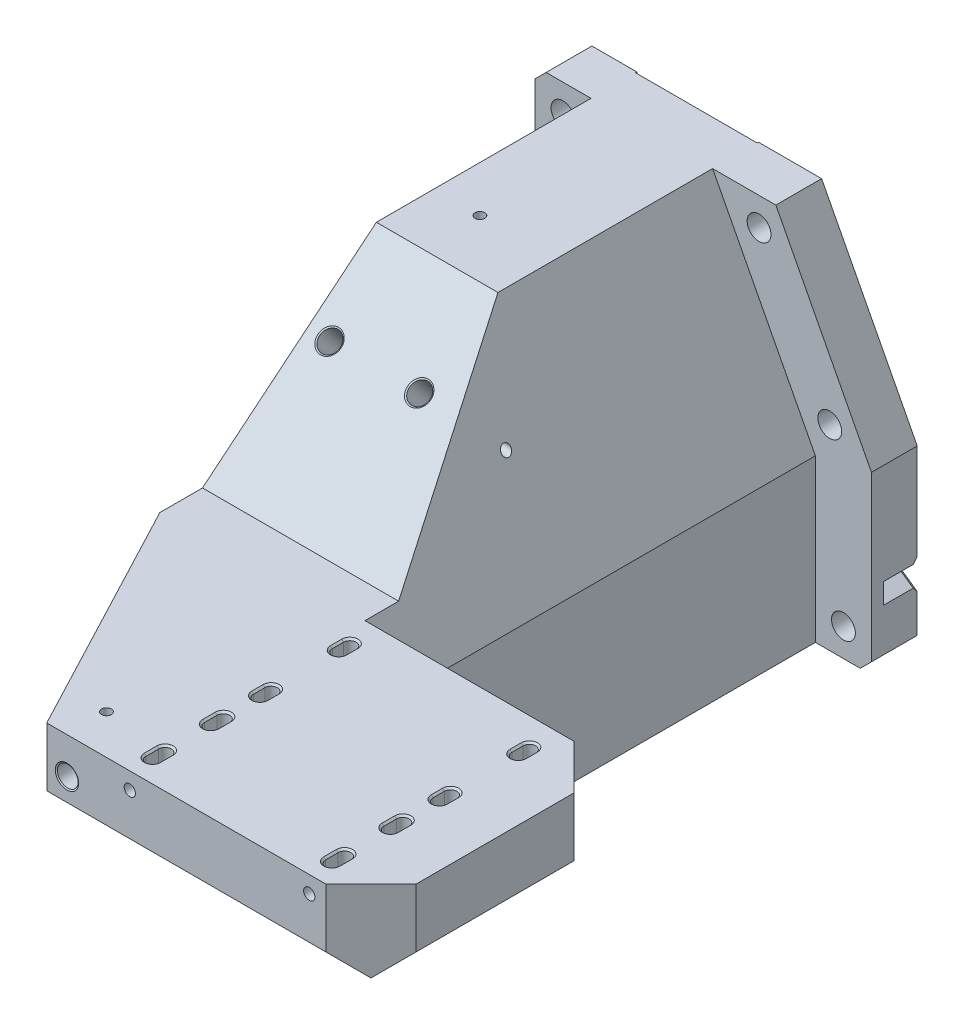
from build123d import *

# Parameters (mm, degrees)
SKETCH1_W                                   = 254.635
SKETCH1_H                                   = 101.6
EXTRUDE1_DEPTH                              = 341.0712
CUT_EXTRUDE2_DEPTH                          = 1
CUT_EXTRUDE2_DEPTH_BACK                     = 102.6
SKETCH2_W                                   = 31.75
SKETCH2_H                                   = 101.6
EXTRUDE2_DEPTH                              = 25.908
CUT_EXTRUDE15_DEPTH                         = 102.6
SKETCH36_W                                  = 176.53
SKETCH36_H                                  = 69.85
CUT_EXTRUDE19_DEPTH                         = 6.35
CUT_EXTRUDE22_DEPTH                         = 82.55
CUT_EXTRUDE23_DEPTH                         = 1
CUT_EXTRUDE23_DEPTH_BACK                    = 102.6
SKETCH46_W                                  = 190.5
SKETCH46_H                                  = 25.908
EXTRUDE7_DEPTH                              = 101.6
EXTRUDE8_DEPTH                              = 127
CUT_EXTRUDE26_DEPTH                         = 101.6
CUT_EXTRUDE27_DEPTH                         = 79.375
CUT_EXTRUDE28_DEPTH                         = 38.9382
CUT_EXTRUDE30_DEPTH                         = 26.908
EXTRUDE9_DEPTH                              = 82.55
SKETCH58_W                                  = 48.895
SKETCH58_H                                  = 6.35
CUT_EXTRUDE34_DEPTH                         = 3.175
SKETCH59_W                                  = 127.635
SKETCH59_H                                  = 95.25
EXTRUDE10_DEPTH                             = 25.4
EXTRUDE11_DEPTH                             = 26.924
SKETCH64_W                                  = 183.515
SKETCH64_H                                  = 122.174
EXTRUDE12_DEPTH                             = 64.008
EXTRUDE13_DEPTH                             = 123.174
LPATTERN2_COUNT                             = 2
LPATTERN2_PITCH                             = 101.6
LPATTERN2_COUNT_DIR2                        = 2
LPATTERN2_PITCH_DIR2                        = 33.02
EXTRUDE17_DEPTH                             = 122.174
EXTRUDE18_DEPTH                             = 255.635
EXTRUDE19_REACH                             = 256.635
EXTRUDE20_DEPTH                             = 406.0792
EXTRUDE21_DEPTH                             = 19.05
CHAMFER3_SIZE                               = 25.4
TAPPED_HOLE_FOR_3_8_16_HELICOIL2_AT_2_COUNT = 2
TAPPED_HOLE_FOR_3_8_16_HELICOIL2_AT_2_PITCH = 50.8
TAPPED_HOLE_FOR_3_8_16_HELICOIL1_AT_2_COUNT = 2
TAPPED_HOLE_FOR_3_8_16_HELICOIL1_AT_2_PITCH = 50.8
TAPPED_HOLE_FOR_3_8_16_HELICOIL1_AT_3_COUNT = 2
TAPPED_HOLE_FOR_3_8_16_HELICOIL1_AT_3_PITCH = 126.55752319
TAPPED_HOLE_FOR_3_8_16_HELICOIL1_AT_4_COUNT = 2
TAPPED_HOLE_FOR_3_8_16_HELICOIL1_AT_4_PITCH = 86.45743621
F_7_32_0_21875_DIAMETER_HOLE1_D             = 5.55625
F_7_32_0_21875_DIAMETER_HOLE3_D             = 5.55625
F_7_32_0_21875_DIAMETER_HOLE3_DEPTH         = 72.262
F_7_32_0_21875_DIAMETER_HOLE4_D             = 5.55625
F_7_32_0_21875_DIAMETER_HOLE4_DEPTH         = 72.262
CHAMFER5_SIZE                               = 1.016
F_17_32_0_53125_DIAMETER_HOLE1_AT_2_COUNT   = 2
F_17_32_0_53125_DIAMETER_HOLE1_AT_2_PITCH   = 85.725
F_17_32_0_53125_DIAMETER_HOLE1_AT_3_COUNT   = 2
F_17_32_0_53125_DIAMETER_HOLE1_AT_3_PITCH   = 171.45
F_17_32_0_53125_DIAMETER_HOLE1_AT_4_COUNT   = 2
F_17_32_0_53125_DIAMETER_HOLE1_AT_4_PITCH   = 204.24411498
F_17_32_0_53125_DIAMETER_HOLE1_AT_5_COUNT   = 2
F_17_32_0_53125_DIAMETER_HOLE1_AT_5_PITCH   = 178.358275505
F_17_32_0_53125_DIAMETER_HOLE1_AT_6_COUNT   = 2
F_17_32_0_53125_DIAMETER_HOLE1_AT_6_PITCH   = 158.75
F_3_8_0_375_DIAMETER_HOLE2_D                = 9.54278
F_3_8_0_375_DIAMETER_HOLE2_CSINK_D          = 14.224
F_3_8_0_375_DIAMETER_HOLE2_CSINK_ANGLE      = 90
EXTRUDE23_DEPTH                             = 19.05
CHAMFER6_SIZE                               = 2.286
EXTRUDE24_DEPTH                             = 0.762
CHAMFER2_SIZE                               = 6.35
SKETCH113_R                                 = 11.1125
EXTRUDE25_DEPTH                             = 99.06
F_1_4_0_25_DIAMETER_HOLE1_D                 = 6.35
F_1_4_0_25_DIAMETER_HOLE1_DEPTH             = 116.84
F_1_4_0_25_DIAMETER_HOLE1_TIP               = 1.907732465
F_7_32_0_21875_DIAMETER_HOLE5_D             = 5.55625


with BuildPart() as part:
    # Sketch1 → Extrude1 (new body)
    with BuildSketch(Plane.XY):
        Rectangle(SKETCH1_W, SKETCH1_H)
    extrude(amount=EXTRUDE1_DEPTH)

    # Sketch5 → Cut-Extrude2 (cut, two sides)
    with BuildSketch(Plane(origin=(0, 50.8, 0), x_dir=(-1, 0, 0), z_dir=(0, 1, 0))) as cut_extrude2_sk:
        Polygon((0.3175, -754.042801335), (0.3175, 0), (0.3175, 271.2212), (-127.3175, 271.2212), (-881.360301335, 271.2212), (-2024.795627832, -712.078265623), (-1143.117826498, -1737.342266958), align=None)
    extrude(amount=CUT_EXTRUDE2_DEPTH, mode=Mode.SUBTRACT)
    extrude(cut_extrude2_sk.sketch, amount=-CUT_EXTRUDE2_DEPTH_BACK, mode=Mode.SUBTRACT)

    # Sketch2 → Extrude2 (add)
    with BuildSketch(Plane(origin=(0, 0, 0), x_dir=(-1, 0, 0), z_dir=(0, 0, -1))):
        with Locations((143.1925, 0)):
            Rectangle(SKETCH2_W, SKETCH2_H)
        with Locations((-15.5575, 0)):
            Rectangle(SKETCH2_W, SKETCH2_H)
    extrude(amount=-EXTRUDE2_DEPTH)

    # Sketch26 → Cut-Extrude15 (cut, through all)
    with BuildSketch(Plane(origin=(0, 50.8, 0), x_dir=(-1, 0, 0), z_dir=(0, 1, 0))):
        with BuildLine():
            Line((12.7762, 280.4922), (12.7762, 286.8422))
            ThreePointArc((12.7762, 286.8422), (9.2075, 290.4109), (5.6388, 286.8422))
            Line((5.6388, 286.8422), (5.6388, 280.4922))
            ThreePointArc((5.6388, 280.4922), (9.2075, 276.9235), (12.7762, 280.4922))
        make_face()
        with BuildLine():
            Line((5.6388, 331.4192), (5.6388, 325.0692))
            ThreePointArc((5.6388, 325.0692), (9.2075, 321.5005), (12.7762, 325.0692))
            Line((12.7762, 325.0692), (12.7762, 331.4192))
            ThreePointArc((12.7762, 331.4192), (9.2075, 334.9879), (5.6388, 331.4192))
        make_face()
        with BuildLine():
            Line((-95.9612, 331.4192), (-95.9612, 325.0692))
            ThreePointArc((-95.9612, 325.0692), (-92.3925, 321.5005), (-88.8238, 325.0692))
            Line((-88.8238, 325.0692), (-88.8238, 331.4192))
            ThreePointArc((-88.8238, 331.4192), (-92.3925, 334.9879), (-95.9612, 331.4192))
        make_face()
        with BuildLine():
            Line((-88.8238, 280.4922), (-88.8238, 286.8422))
            ThreePointArc((-88.8238, 286.8422), (-92.3925, 290.4109), (-95.9612, 286.8422))
            Line((-95.9612, 286.8422), (-95.9612, 280.4922))
            ThreePointArc((-95.9612, 280.4922), (-92.3925, 276.9235), (-88.8238, 280.4922))
        make_face()
    extrude(amount=-CUT_EXTRUDE15_DEPTH, mode=Mode.SUBTRACT)

    # Sketch36 → Cut-Extrude19 (cut)
    with BuildSketch(Plane(origin=(0, 50.8, 0), x_dir=(-1, 0, 0), z_dir=(0, 1, 0))):
        with Locations((-39.0525, 306.1462)):
            Rectangle(SKETCH36_W, SKETCH36_H)
    extrude(amount=-CUT_EXTRUDE19_DEPTH, mode=Mode.SUBTRACT)

    # Sketch39 → Cut-Extrude22 (cut)
    with BuildSketch(Plane.XZ.offset(50.8)):
        with BuildLine():
            Line((66.9925, 331.5462), (41.5925, 331.5462))
            Line((41.5925, 331.5462), (16.1925, 331.5462))
            ThreePointArc((16.1925, 331.5462), (7.212243879, 327.826456121), (3.4925, 318.8462))
            Line((3.4925, 318.8462), (3.4925, 293.4462))
            ThreePointArc((3.4925, 293.4462), (7.212243879, 284.465943879), (16.1925, 280.7462))
            Line((16.1925, 280.7462), (41.5925, 280.7462))
            Line((41.5925, 280.7462), (66.9925, 280.7462))
            ThreePointArc((66.9925, 280.7462), (75.972756121, 284.465943879), (79.6925, 293.4462))
            Line((79.6925, 293.4462), (79.6925, 318.8462))
            ThreePointArc((79.6925, 318.8462), (75.972756121, 327.826456121), (66.9925, 331.5462))
        make_face()
    extrude(amount=-CUT_EXTRUDE22_DEPTH, mode=Mode.SUBTRACT)

    # Sketch31 → Cut-Extrude23 (cut, two sides)
    with BuildSketch(Plane(origin=(0, 50.8, 0), x_dir=(-1, 0, 0), z_dir=(0, 1, 0))) as cut_extrude23_sk:
        Polygon((-498.609487201, 895.878187201), (56.1975, 341.0712), (127.3175, 269.9512), (682.124487201, -284.855787201), (1791.738461603, 824.758187201), (611.004487201, 2005.492161603), align=None)
    extrude(amount=CUT_EXTRUDE23_DEPTH, mode=Mode.SUBTRACT)
    extrude(cut_extrude23_sk.sketch, amount=-CUT_EXTRUDE23_DEPTH_BACK, mode=Mode.SUBTRACT)

    # Sketch46 → Extrude7 (add)
    with BuildSketch(Plane(origin=(0, 50.8, 0), x_dir=(-1, 0, 0), z_dir=(0, 1, 0))):
        with Locations((63.8175, 12.954)):
            Rectangle(SKETCH46_W, SKETCH46_H)
    extrude(amount=EXTRUDE7_DEPTH)

    # Sketch47 → Extrude8 (add)
    with BuildSketch(Plane.ZY.offset(127.3175)):
        Polygon((25.908, 152.4), (147.3962, 152.4), (248.9962, 50.8), (25.908, 50.8), align=None)
    extrude(amount=-EXTRUDE8_DEPTH)

    # Sketch49 → Cut-Extrude26 (cut)
    with BuildSketch(Plane.XY.offset(64.8462)):
        Polygon((31.4325, -20.32), (-58.479840971, 152.4), (31.4325, 152.4), align=None)
    extrude(amount=CUT_EXTRUDE26_DEPTH, mode=Mode.SUBTRACT)

    # Sketch50 → Cut-Extrude27 (cut)
    with BuildSketch(Plane(origin=(0, 0, 166.4462), x_dir=(-1, 0, 0), z_dir=(0, 0, -1))):
        Polygon((48.563038658, 133.35), (0.3175, 133.35), (0.3175, 40.671182531), align=None)
    extrude(amount=-CUT_EXTRUDE27_DEPTH, mode=Mode.SUBTRACT)

    # Sketch51 → Cut-Extrude28 (cut)
    with BuildSketch(Plane.XY.offset(64.8462)):
        Polygon((-0.3175, 40.671182531), (-0.3175, 152.4), (-58.479840971, 152.4), align=None)
    extrude(amount=-CUT_EXTRUDE28_DEPTH, mode=Mode.SUBTRACT)

    # Sketch52 → Cut-Extrude30 (cut, through all)
    with BuildSketch(Plane.XY.offset(25.908)):
        Polygon((-22.685464158, 152.4), (31.4325, 48.440358104), (31.4325, 152.4), align=None)
    extrude(amount=-CUT_EXTRUDE30_DEPTH, mode=Mode.SUBTRACT)

    # Sketch54 → Extrude9 (add)
    with BuildSketch(Plane.XZ.offset(-31.75)):
        with BuildLine():
            Line((66.9925, 331.5462), (16.1925, 331.5462))
            ThreePointArc((16.1925, 331.5462), (7.212243879, 327.826456121), (3.4925, 318.8462))
            Line((3.4925, 318.8462), (3.4925, 293.4462))
            ThreePointArc((3.4925, 293.4462), (7.212243879, 284.465943879), (16.1925, 280.7462))
            Line((16.1925, 280.7462), (66.9925, 280.7462))
            ThreePointArc((66.9925, 280.7462), (75.972756121, 284.465943879), (79.6925, 293.4462))
            Line((79.6925, 293.4462), (79.6925, 318.8462))
            ThreePointArc((79.6925, 318.8462), (75.972756121, 327.826456121), (66.9925, 331.5462))
        make_face()
    extrude(amount=EXTRUDE9_DEPTH)

    # Sketch58 → Cut-Extrude34 (cut)
    with BuildSketch(Plane.XY.offset(271.2212)):
        with Locations((-24.765, 47.625)):
            Rectangle(SKETCH58_W, SKETCH58_H)
    extrude(amount=-CUT_EXTRUDE34_DEPTH, mode=Mode.SUBTRACT)

    # Sketch59 → Extrude10 (add)
    with BuildSketch(Plane(origin=(0, 0, 271.2212), x_dir=(-1, 0, 0), z_dir=(0, 0, -1))):
        with Locations((-63.5, -3.175)):
            Rectangle(SKETCH59_W, SKETCH59_H)
    extrude(amount=EXTRUDE10_DEPTH)

    # Sketch63 → Extrude11 (add)
    with BuildSketch(Plane(origin=(0, 44.45, 0), x_dir=(1, 0, 0), z_dir=(0, 1, 0))):
        Polygon((-127.3175, -245.8212), (-127.3175, -269.9512), (-56.1975, -341.0712), (127.3175, -341.0712), (127.3175, -245.8212), align=None)
        with BuildLine():
            Line((-12.7762, -331.4192), (-12.7762, -325.0692))
            ThreePointArc((-12.7762, -325.0692), (-9.2075, -321.5005), (-5.6388, -325.0692))
            Line((-5.6388, -325.0692), (-5.6388, -331.4192))
            ThreePointArc((-5.6388, -331.4192), (-9.2075, -334.9879), (-12.7762, -331.4192))
        make_face(mode=Mode.SUBTRACT)
        with BuildLine():
            Line((-5.6388, -280.4922), (-5.6388, -286.8422))
            ThreePointArc((-5.6388, -286.8422), (-9.2075, -290.4109), (-12.7762, -286.8422))
            Line((-12.7762, -286.8422), (-12.7762, -280.4922))
            ThreePointArc((-12.7762, -280.4922), (-9.2075, -276.9235), (-5.6388, -280.4922))
        make_face(mode=Mode.SUBTRACT)
        with BuildLine():
            Line((88.8238, -331.4192), (88.8238, -325.0692))
            ThreePointArc((88.8238, -325.0692), (92.3925, -321.5005), (95.9612, -325.0692))
            Line((95.9612, -325.0692), (95.9612, -331.4192))
            ThreePointArc((95.9612, -331.4192), (92.3925, -334.9879), (88.8238, -331.4192))
        make_face(mode=Mode.SUBTRACT)
        with BuildLine():
            Line((88.8238, -286.8422), (88.8238, -280.4922))
            ThreePointArc((88.8238, -280.4922), (92.3925, -276.9235), (95.9612, -280.4922))
            Line((95.9612, -280.4922), (95.9612, -286.8422))
            ThreePointArc((95.9612, -286.8422), (92.3925, -290.4109), (88.8238, -286.8422))
        make_face(mode=Mode.SUBTRACT)
    extrude(amount=EXTRUDE11_DEPTH)

    # Sketch64 → Extrude12 (add)
    with BuildSketch(Plane.XY.offset(341.0712)):
        with Locations((35.56, 10.287)):
            Rectangle(SKETCH64_W, SKETCH64_H)
    extrude(amount=EXTRUDE12_DEPTH)

    # Sketch67 → Extrude13 (cut, through all)
    with BuildSketch(Plane(origin=(0, 71.374, 0), x_dir=(1, 0, 0), z_dir=(0, 1, 0))):
        with BuildLine():
            Line((-5.6388, -352.1075), (-5.6388, -359.2449))
            ThreePointArc((-5.6388, -359.2449), (-9.2075, -362.8136), (-12.7762, -359.2449))
            Line((-12.7762, -359.2449), (-12.7762, -352.1075))
            ThreePointArc((-12.7762, -352.1075), (-9.2075, -348.5388), (-5.6388, -352.1075))
        make_face()
    extrude13 = extrude(amount=-EXTRUDE13_DEPTH, mode=Mode.SUBTRACT)

    # LPattern2: Extrude13 2 × 2
    with Locations(*[(i * LPATTERN2_PITCH, 0, j * LPATTERN2_PITCH_DIR2) for i in range(LPATTERN2_COUNT) for j in range(LPATTERN2_COUNT_DIR2) if (i, j) != (0, 0)]):
        add(extrude13, mode=Mode.SUBTRACT)

    # Sketch69 → Extrude17 (add)
    with BuildSketch(Plane.XZ.offset(50.8)):
        Polygon((-56.1975, 405.0792), (-56.1975, 341.0712), (-127.3175, 269.9512), align=None)
    extrude(amount=-EXTRUDE17_DEPTH)

    # Sketch70 → Extrude18 (cut, through all)
    with BuildSketch(Plane.ZY.offset(127.3175)):
        Polygon((405.0792, 38.1), (405.0792, -50.8), (316.1792, -50.8), align=None)
    extrude(amount=-EXTRUDE18_DEPTH, mode=Mode.SUBTRACT)

    # Extrude19: up to this plane
    extrude19_end = Plane(origin=(31.4325, -20.32, 166.4462), z_dir=(0.887010833, 0.461748613, 0))
    # Sketch71 → Extrude19 (add, up to the surface)
    with BuildSketch(Plane.ZY.offset(127.3175), mode=Mode.PRIVATE) as extrude19_sk1:
        Polygon((245.8212, 71.374), (245.8212, 53.975), (147.3962, 152.4), align=None)
    extrude19_tool1 = split(extrude(extrude19_sk1.sketch, amount=-EXTRUDE19_REACH, mode=Mode.PRIVATE), bisect_by=extrude19_end, keep=Keep.BOTH, mode=Mode.PRIVATE)
    add(extrude19_tool1.solids().sort_by_distance((-127.3175, 92.583, 213.012867))[0])

    # Sketch72 → Extrude20 (cut, through all)
    with BuildSketch(Plane.XY.offset(405.0792)):
        Polygon((127.3175, 38.1), (38.4175, -50.8), (127.3175, -50.8), align=None)
    extrude(amount=-EXTRUDE20_DEPTH, mode=Mode.SUBTRACT)

    # Sketch75 → Extrude21 (cut)
    with BuildSketch(Plane(origin=(0, 0, 245.8212), x_dir=(-1, 0, 0), z_dir=(0, 0, -1))):
        Polygon((-127.3175, 38.1), (-38.4175, -50.8), (0.3175, -50.8), (0.3175, 40.671182531), (16.300375133, 71.374), (-127.3175, 71.374), align=None)
    extrude(amount=-EXTRUDE21_DEPTH, mode=Mode.SUBTRACT)

    # Chamfer3
    chamfer3_edges = [part.edges().sort_by_distance(p)[0] for p in [
        (127.3175, 54.737, 405.0792),
        (127.3175, 54.737, 264.8712),
    ]]
    chamfer(chamfer3_edges, length=CHAMFER3_SIZE)

    # Sketch80 → Tapped Hole for 3/8-16 Helicoil2 (revolve, cut)
    with BuildSketch(Plane(origin=(-63.8175, 120.113167402, 186.616098531), x_dir=(0, -0.635567571, 0.772045247), z_dir=(1, 0, 0))):
        Polygon((0, 0), (0, 32.163279155), (5.0419, 29.1338), (5.0419, 22.86), (5.84454, 22.86), (5.84454, 0.438474435), (6.604, 0), align=None)
    tapped_hole_for_3_8_16_helicoil2 = revolve(axis=Axis((-63.8175, 125.015654719, 190.651952606), (0, -0.772045247, -0.635567571)), mode=Mode.SUBTRACT)

    # Tapped Hole for 3/8-16 Helicoil2 at 2: Tapped Hole for 3/8-16 Helicoil2 ×2
    with Locations(*[(-i * TAPPED_HOLE_FOR_3_8_16_HELICOIL2_AT_2_PITCH, 0, 0) for i in range(1, TAPPED_HOLE_FOR_3_8_16_HELICOIL2_AT_2_COUNT)]):
        add(tapped_hole_for_3_8_16_helicoil2, mode=Mode.SUBTRACT)

    # Sketch82 → Tapped Hole for 3/8-16 Helicoil1 (revolve, cut)
    with BuildSketch(Plane(origin=(-127.3175, 21.463, 178.308), x_dir=(0, 0, 1), z_dir=(0, 1, 0))):
        Polygon((0, 0), (0, 32.163279155), (5.0419, 29.1338), (5.0419, 22.86), (5.84454, 22.86), (5.84454, 0.438474435), (6.604, 0), align=None)
    tapped_hole_for_3_8_16_helicoil1 = revolve(axis=Axis((-133.6675, 21.463, 178.308), (1, 0, 0)), mode=Mode.SUBTRACT)

    # Tapped Hole for 3/8-16 Helicoil1 at 2: Tapped Hole for 3/8-16 Helicoil1 ×2
    with Locations(*[(0, -i * TAPPED_HOLE_FOR_3_8_16_HELICOIL1_AT_2_PITCH, 0) for i in range(1, TAPPED_HOLE_FOR_3_8_16_HELICOIL1_AT_2_COUNT)]):
        add(tapped_hole_for_3_8_16_helicoil1, mode=Mode.SUBTRACT)

    # Tapped Hole for 3/8-16 Helicoil1 at 3: Tapped Hole for 3/8-16 Helicoil1 ×2
    with Locations(*[Vector(0, 0.865013768, -0.501748125) * (i * TAPPED_HOLE_FOR_3_8_16_HELICOIL1_AT_3_PITCH) for i in range(1, TAPPED_HOLE_FOR_3_8_16_HELICOIL1_AT_3_COUNT)]):
        add(tapped_hole_for_3_8_16_helicoil1, mode=Mode.SUBTRACT)

    # Tapped Hole for 3/8-16 Helicoil1 at 4: Tapped Hole for 3/8-16 Helicoil1 ×2
    with Locations(*[Vector(0, 0.678646078, -0.734465452) * (i * TAPPED_HOLE_FOR_3_8_16_HELICOIL1_AT_4_PITCH) for i in range(1, TAPPED_HOLE_FOR_3_8_16_HELICOIL1_AT_4_COUNT)]):
        add(tapped_hole_for_3_8_16_helicoil1, mode=Mode.SUBTRACT)

    # 7/32 (0.21875) Diameter Hole1 (through all)
    with Locations(Plane.ZY.offset(127.3175)):
        with Locations((170.09331195, 100.042384329)):
            Hole(F_7_32_0_21875_DIAMETER_HOLE1_D / 2)

    # 7/32 (0.21875) Diameter Hole3
    with Locations(Plane(origin=(0, 152.4, 0), x_dir=(-1, 0, 0), z_dir=(0, 1, 0))):
        with Locations((101.3206, 114.808)):
            Hole(F_7_32_0_21875_DIAMETER_HOLE3_D / 2, depth=F_7_32_0_21875_DIAMETER_HOLE3_DEPTH)

    # 7/32 (0.21875) Diameter Hole4
    with Locations(Plane.XZ.offset(50.8)):
        with Locations((-101.3206, 178.308)):
            Hole(F_7_32_0_21875_DIAMETER_HOLE4_D / 2, depth=F_7_32_0_21875_DIAMETER_HOLE4_DEPTH)

    # Sketch102 → Tapped Hole for 3/8-16 Helicoil3 (revolve, cut)
    with BuildSketch(Plane(origin=(-44.7675, 50.8, 405.0792), x_dir=(0, -1, 0), z_dir=(1, 0, 0))):
        Polygon((0, 0), (0, 25.381479155), (5.0419, 22.352), (5.0419, 11.176), (5.84454, 11.176), (5.84454, 0.438474435), (6.604, 0), align=None)
    revolve(axis=Axis((-44.7675, 50.8, 411.4292), (0, 0, -1)), mode=Mode.SUBTRACT)

    # Chamfer5
    chamfer5_edges = [part.edges().sort_by_distance(p)[0] for p in [
        (-9.2075, 71.374, 334.9879),
        (-5.6388, 71.374, 328.2442),
        (-9.2075, 71.374, 321.5005),
        (-12.7762, 71.374, 328.2442),
        (-9.2075, 71.374, 290.4109),
        (-5.6388, 71.374, 283.6672),
        (-9.2075, 71.374, 276.9235),
        (-12.7762, 71.374, 283.6672),
        (92.3925, 71.374, 334.9879),
        (95.9612, 71.374, 328.2442),
        (92.3925, 71.374, 321.5005),
        (88.8238, 71.374, 328.2442),
        (92.3925, 71.374, 290.4109),
        (95.9612, 71.374, 283.6672),
        (92.3925, 71.374, 276.9235),
        (88.8238, 71.374, 283.6672),
        (-9.2075, 71.374, 348.5388),
        (-12.7762, 71.374, 355.6762),
        (-9.2075, 71.374, 362.8136),
        (-5.6388, 71.374, 355.6762),
        (92.3925, 71.374, 348.5388),
        (88.8238, 71.374, 355.6762),
        (92.3925, 71.374, 362.8136),
        (95.9612, 71.374, 355.6762),
        (-9.2075, 71.374, 381.5588),
        (-5.6388, 71.374, 388.6962),
        (-9.2075, 71.374, 395.8336),
        (-12.7762, 71.374, 388.6962),
        (92.3925, 71.374, 381.5588),
        (95.9612, 71.374, 388.6962),
        (92.3925, 71.374, 395.8336),
        (88.8238, 71.374, 388.6962),
    ]]
    chamfer(chamfer5_edges, length=CHAMFER5_SIZE)

    # Sketch107 → 17/32 (0.53125) Diameter Hole1 (revolve, cut)
    with BuildSketch(Plane(origin=(-143.1925, -34.925, 25.908), x_dir=(0, -1, 0), z_dir=(1, 0, 0))):
        Polygon((0, 0), (0, 25.908), (9.525, 25.908), (6.746875, 23.129875), (6.746875, 0), align=None)
    f_17_32_0_53125_diameter_hole1 = revolve(axis=Axis((-143.1925, -34.925, 32.258), (0, 0, -1)), mode=Mode.SUBTRACT)

    # 17/32 (0.53125) Diameter Hole1 at 2: 17/32 (0.53125) Diameter Hole1 ×2
    with Locations(*[(0, i * F_17_32_0_53125_DIAMETER_HOLE1_AT_2_PITCH, 0) for i in range(1, F_17_32_0_53125_DIAMETER_HOLE1_AT_2_COUNT)]):
        add(f_17_32_0_53125_diameter_hole1, mode=Mode.SUBTRACT)

    # 17/32 (0.53125) Diameter Hole1 at 3: 17/32 (0.53125) Diameter Hole1 ×2
    with Locations(*[(0, i * F_17_32_0_53125_DIAMETER_HOLE1_AT_3_PITCH, 0) for i in range(1, F_17_32_0_53125_DIAMETER_HOLE1_AT_3_COUNT)]):
        add(f_17_32_0_53125_diameter_hole1, mode=Mode.SUBTRACT)

    # 17/32 (0.53125) Diameter Hole1 at 4: 17/32 (0.53125) Diameter Hole1 ×2
    with Locations(*[Vector(0.543457519, 0.839436671, 0) * (i * F_17_32_0_53125_DIAMETER_HOLE1_AT_4_PITCH) for i in range(1, F_17_32_0_53125_DIAMETER_HOLE1_AT_4_COUNT)]):
        add(f_17_32_0_53125_diameter_hole1, mode=Mode.SUBTRACT)

    # 17/32 (0.53125) Diameter Hole1 at 5: 17/32 (0.53125) Diameter Hole1 ×2
    with Locations(*[Vector(0.846627383, 0.532186128, 0) * (i * F_17_32_0_53125_DIAMETER_HOLE1_AT_5_PITCH) for i in range(1, F_17_32_0_53125_DIAMETER_HOLE1_AT_5_COUNT)]):
        add(f_17_32_0_53125_diameter_hole1, mode=Mode.SUBTRACT)

    # 17/32 (0.53125) Diameter Hole1 at 6: 17/32 (0.53125) Diameter Hole1 ×2
    with Locations(*[(i * F_17_32_0_53125_DIAMETER_HOLE1_AT_6_PITCH, 0, 0) for i in range(1, F_17_32_0_53125_DIAMETER_HOLE1_AT_6_COUNT)]):
        add(f_17_32_0_53125_diameter_hole1, mode=Mode.SUBTRACT)

    # 3/8 (0.375) Diameter Hole2 (through all)
    with Locations(Plane(origin=(0, 0, 0), x_dir=(-1, 0, 0), z_dir=(0, 0, -1))):
        with Locations((143.1925, 107.95)):
            CounterSinkHole(F_3_8_0_375_DIAMETER_HOLE2_D / 2, F_3_8_0_375_DIAMETER_HOLE2_CSINK_D / 2, counter_sink_angle=F_3_8_0_375_DIAMETER_HOLE2_CSINK_ANGLE)

    # Sketch111 → Extrude23 (cut)
    with BuildSketch(Plane(origin=(0, 0, 0), x_dir=(-1, 0, 0), z_dir=(0, 0, -1))):
        with BuildLine():
            Line((-7.517242222, -3.393211611), (-33.686073969, -21.716824866))
            ThreePointArc((-33.686073969, -21.716824866), (-40.318943358, -20.547271034), (-39.149389525, -13.914401644))
            Line((-39.149389525, -13.914401644), (-12.980557778, 4.409211611))
            ThreePointArc((-12.980557778, 4.409211611), (-6.347688389, 3.239657778), (-7.517242222, -3.393211611))
        make_face()
    extrude(amount=-EXTRUDE23_DEPTH, mode=Mode.SUBTRACT)

    # Chamfer6
    chamfer6_edges = [part.edges().sort_by_distance(p)[0] for p in [
        (19.474871111, -11.766033498, 0),
        (6.347688389, 3.239657778, 0),
        (22.206528889, -2.050882908, 0),
    ]]
    chamfer(chamfer6_edges, length=CHAMFER6_SIZE)

    # Sketch112 → Extrude24 (cut)
    with BuildSketch(Plane(origin=(0, 0, 0), x_dir=(-1, 0, 0), z_dir=(0, 0, -1))):
        with BuildLine():
            Line((58.479840971, 152.4), (1.034981209, 42.049451111))
            ThreePointArc((1.034981209, 42.049451111), (0.499477857, 40.626652833), (0.3175, 39.117347417))
            Line((0.3175, 39.117347417), (0.3175, -50.8))
            Line((0.3175, -50.8), (127.3175, -50.8))
            Line((127.3175, -50.8), (127.3175, 152.4))
            Line((127.3175, 152.4), (58.479840971, 152.4))
        make_face()
    extrude(amount=-EXTRUDE24_DEPTH, mode=Mode.SUBTRACT)

    # Chamfer2
    chamfer2_edges = [part.edges().sort_by_distance(p)[0] for p in [
        (-159.0675, 152.4, 12.954),
        (-159.0675, -50.8, 12.954),
        (31.4325, -50.8, 12.954),
    ]]
    chamfer(chamfer2_edges, length=CHAMFER2_SIZE)

    # Sketch113 → Extrude25 (cut)
    with BuildSketch(Plane.XZ.offset(50.8)):
        with Locations(Location((-9.2075, 283.6672, 0), (0, 0, 270))):  # turned: the seam where the file's is
            Circle(SKETCH113_R)
        with Locations(Location((-9.2075, 328.2442, 0), (0, 0, 270))):  # turned: the seam where the file's is
            Circle(SKETCH113_R)
        with Locations(Location((-9.2075, 355.6762, 0), (0, 0, 270))):  # turned: the seam where the file's is
            Circle(SKETCH113_R)
        with Locations(Location((-9.2075, 388.6962, 0), (0, 0, 270))):  # turned: the seam where the file's is
            Circle(SKETCH113_R)
        with Locations(Location((92.3925, 388.6962, 0), (0, 0, 270))):  # turned: the seam where the file's is
            Circle(SKETCH113_R)
        with Locations(Location((92.3925, 355.6762, 0), (0, 0, 270))):  # turned: the seam where the file's is
            Circle(SKETCH113_R)
        with Locations(Location((92.3925, 328.2442, 0), (0, 0, 270))):  # turned: the seam where the file's is
            Circle(SKETCH113_R)
        with Locations(Location((92.3925, 283.6672, 0), (0, 0, 270))):  # turned: the seam where the file's is
            Circle(SKETCH113_R)
    extrude(amount=-EXTRUDE25_DEPTH, mode=Mode.SUBTRACT)

    # 1/4 (0.25) Diameter Hole1
    with Locations(Plane.XY.offset(405.0792)):
        with Locations((92.3925, 61.849), (-9.2075, 61.849)):
            Hole(F_1_4_0_25_DIAMETER_HOLE1_D / 2, depth=F_1_4_0_25_DIAMETER_HOLE1_DEPTH)
            with Locations((0, 0, -(F_1_4_0_25_DIAMETER_HOLE1_DEPTH + F_1_4_0_25_DIAMETER_HOLE1_TIP / 2))):  # 118° drill point
                Cone(0, F_1_4_0_25_DIAMETER_HOLE1_D / 2, F_1_4_0_25_DIAMETER_HOLE1_TIP, mode=Mode.SUBTRACT)

    # 7/32 (0.21875) Diameter Hole5 (through all)
    with Locations(Plane(origin=(0, 71.374, 0), x_dir=(-1, 0, 0), z_dir=(0, 1, 0))):
        with Locations((44.7675, 382.7272)):
            Hole(F_7_32_0_21875_DIAMETER_HOLE5_D / 2)


solid = part.part
